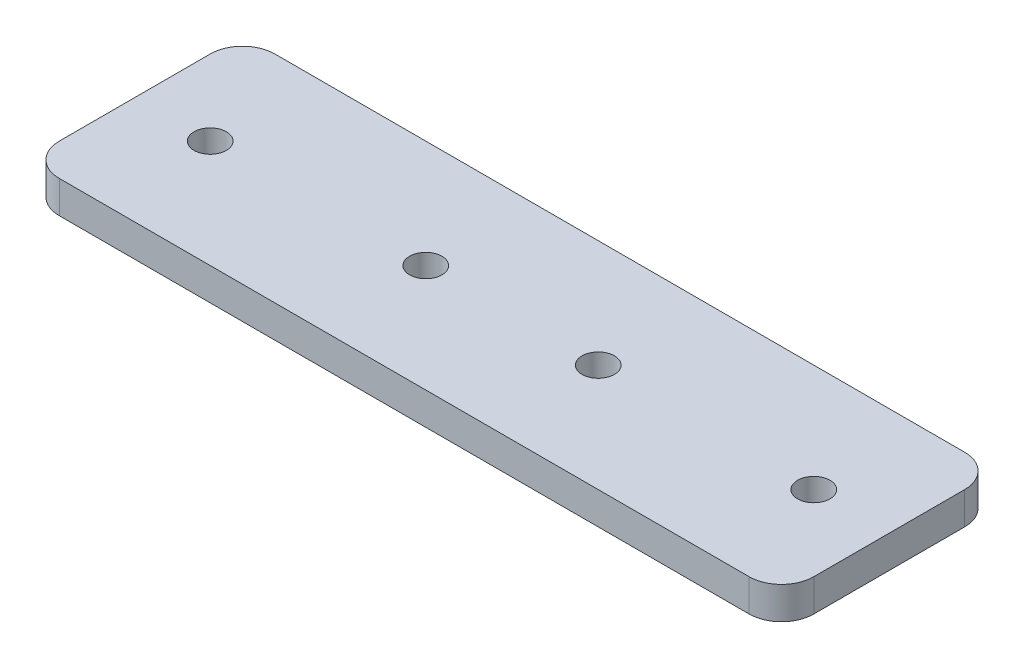
from build123d import *

# Parameters (mm, degrees)
SKETCH1_R           = 1.5
BOSS_EXTRUDE1_DEPTH = 3


with BuildPart() as part:
    # Sketch1 → Boss-Extrude1 (new body)
    with BuildSketch(Plane(origin=(0, 0, 0), x_dir=(1, 0, 0), z_dir=(0, 1, 0))):
        with BuildLine():
            Line((-32, 10), (32, 10))
            ThreePointArc((32, 10), (34.121320344, 9.121320344), (35, 7))
            Line((35, 7), (35, -7))
            ThreePointArc((35, -7), (34.121320344, -9.121320344), (32, -10))
            Line((32, -10), (-32, -10))
            ThreePointArc((-32, -10), (-34.121320344, -9.121320344), (-35, -7))
            Line((-35, -7), (-35, 7))
            ThreePointArc((-35, 7), (-34.121320344, 9.121320344), (-32, 10))
        make_face()
        with Locations((8, 0)):
            Circle(SKETCH1_R, mode=Mode.SUBTRACT)
        with Locations((-8, 0)):
            Circle(SKETCH1_R, mode=Mode.SUBTRACT)
        with Locations((28, 0)):
            Circle(SKETCH1_R, mode=Mode.SUBTRACT)
        with Locations((-28, 0)):
            Circle(SKETCH1_R, mode=Mode.SUBTRACT)
    extrude(amount=BOSS_EXTRUDE1_DEPTH)


solid = part.part
